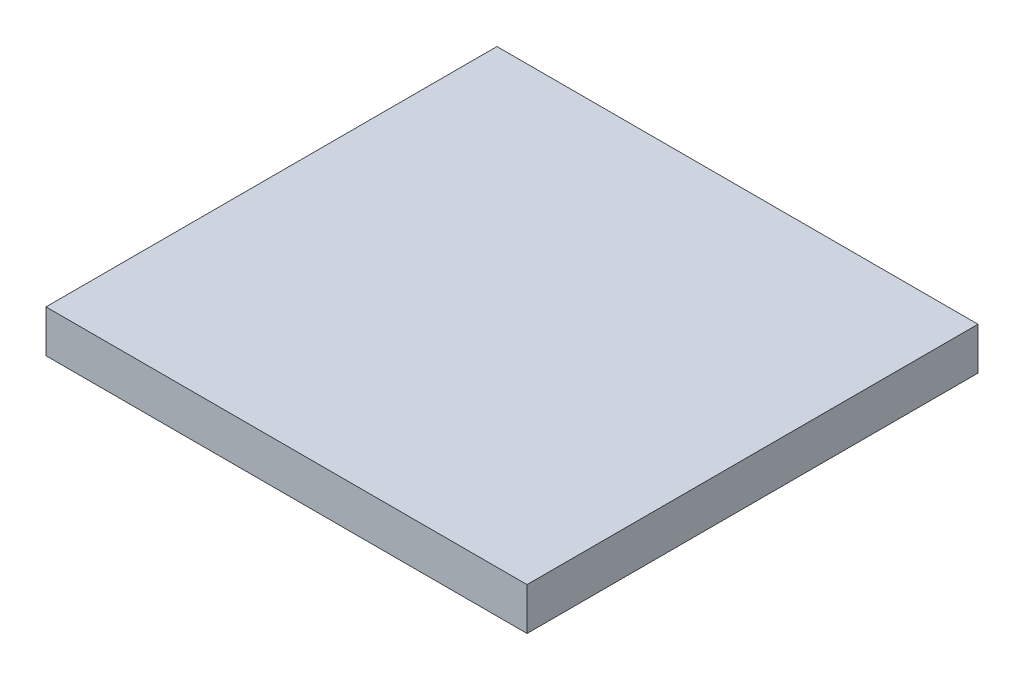
from build123d import *

# Parameters (mm, degrees)
BOSS_EXTRUDE1_START = 5474.868802
SKETCH1_W           = 227.214888822
SKETCH1_H           = 213.013958271
BOSS_EXTRUDE1_DEPTH = 20


with BuildPart() as part:
    # Sketch1 → Boss-Extrude1 (new body)
    with BuildSketch(Plane(origin=(0, 0, 705.937432627), x_dir=(1, 0, 0), z_dir=(0, 1, 0)).offset(BOSS_EXTRUDE1_START)):
        with Locations((-23285.623933291, -40569.778136667)):
            Rectangle(SKETCH1_W, SKETCH1_H)
    extrude(amount=BOSS_EXTRUDE1_DEPTH)


solid = part.part
